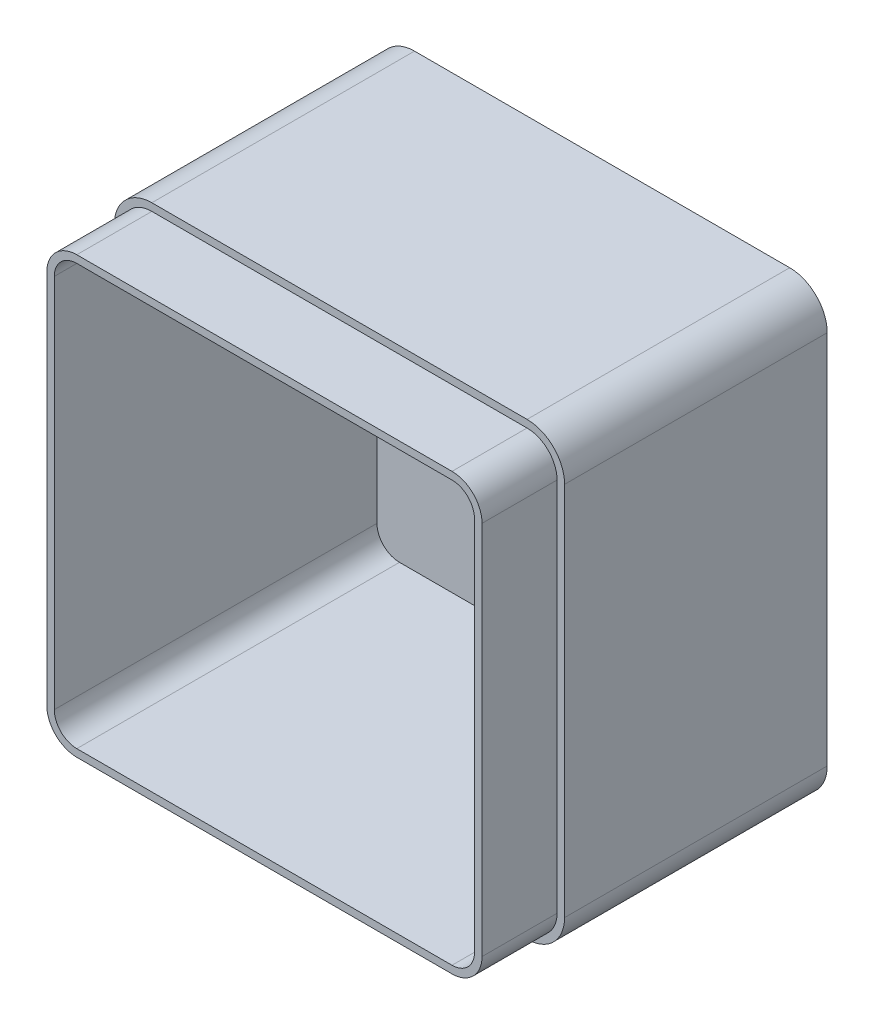
from build123d import *

# Parameters (mm, degrees)
SKETCH1_W           = 120
SKETCH1_H           = 120
BOSS_EXTRUDE1_DEPTH = 90
FILLET1_R           = 10
SHELL1_T            = -4
CUT_EXTRUDE3_DEPTH  = 20


with BuildPart() as part:
    # Sketch1 → Boss-Extrude1 (new body)
    with BuildSketch(Plane.XY):
        with Locations((60, 60)):
            Rectangle(SKETCH1_W, SKETCH1_H)
    extrude(amount=BOSS_EXTRUDE1_DEPTH)

    # Fillet1
    fillet1_edges = [part.edges().sort_by_distance(p)[0] for p in [
        (0, 120, 45),
        (120, 120, 45),
        (120, 0, 45),
        (0, 0, 45),
    ]]
    fillet(fillet1_edges, radius=FILLET1_R)

    # Shell1
    shell1_openings = [part.faces().sort_by_distance(p)[0] for p in [
        (60, 60, 90),
    ]]
    offset(amount=SHELL1_T, openings=shell1_openings, kind=Kind.INTERSECTION)

    # Sketch7 → Cut-Extrude3 (cut)
    with BuildSketch(Plane.XY.offset(90)):
        with BuildLine():
            Line((10, 0), (110, 0))
            ThreePointArc((110, 0), (117.071067812, 2.928932188), (120, 10))
            Line((120, 10), (120, 110))
            ThreePointArc((120, 110), (117.071067812, 117.071067812), (110, 120))
            Line((110, 120), (10, 120))
            ThreePointArc((10, 120), (2.928932188, 117.071067812), (0, 110))
            Line((0, 110), (0, 10))
            ThreePointArc((0, 10), (2.928932188, 2.928932188), (10, 0))
        make_face()
        with BuildLine():
            Line((10, 2), (110, 2))
            ThreePointArc((110, 2), (115.656854249, 4.343145751), (118, 10))
            Line((118, 10), (118, 110))
            ThreePointArc((118, 110), (115.656854249, 115.656854249), (110, 118))
            Line((110, 118), (10, 118))
            ThreePointArc((10, 118), (4.343145751, 115.656854249), (2, 110))
            Line((2, 110), (2, 10))
            ThreePointArc((2, 10), (4.343145751, 4.343145751), (10, 2))
        make_face(mode=Mode.SUBTRACT)
    extrude(amount=-CUT_EXTRUDE3_DEPTH, mode=Mode.SUBTRACT)


solid = part.part
